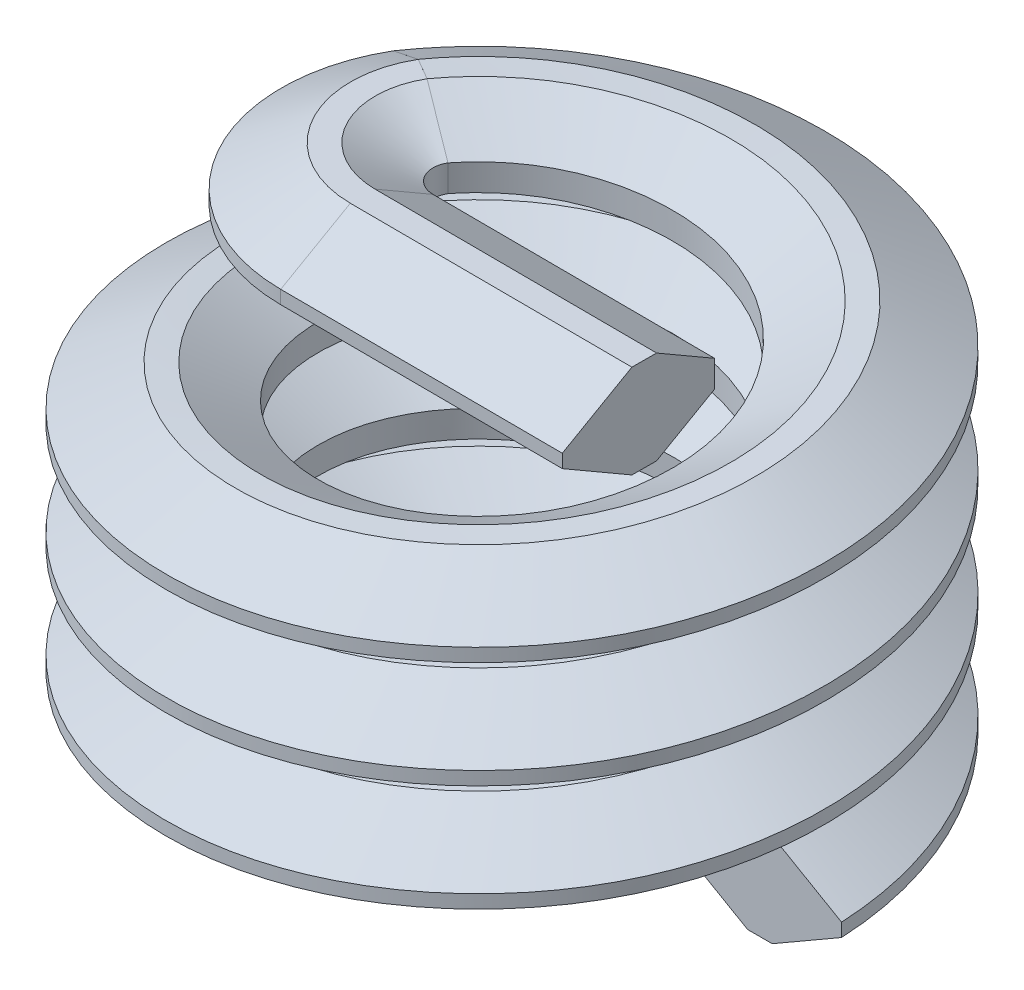
from build123d import *

# Parameters (mm, degrees)
SWEEP1_PITCH       = 0.79375
SWEEP1_HEIGHT      = 2.71145
SWEEP1_RADIUS      = 1.7526
SWEEP1_START_ANGLE = 90
REVOLVE1_ANGLE     = 120
EXTRUDE1_DEPTH     = 2.10312


with BuildPart() as part:
    # Sweep1: sweep along a helix
    with BuildLine() as sweep1_path:
        add(Helix(SWEEP1_PITCH, SWEEP1_HEIGHT, SWEEP1_RADIUS, center=(0, 0, 0), direction=(0, 1, 0), mode=Mode.PRIVATE).rotate(Axis((0, 0, 0), (0, 1, 0)), SWEEP1_START_ANGLE))
    # Sketch1 → Sweep1 (sweep)
    with BuildSketch(Plane(origin=(0, 0, 0), x_dir=(-1, 0, 0), z_dir=(0, 0, 1))):
        Polygon((-2.4511, -0.049609375), (-1.935544252, -0.347265625), (-1.7526, -0.347265625), (-1.32297021, -0.09921875), (-1.32297021, 0.09921875), (-1.7526, 0.347265625), (-1.935544252, 0.347265625), (-2.4511, 0.049609375), align=None)
    sweep(path=sweep1_path.line, is_frenet=True)


with BuildPart() as body_2:
    # Sketch3 → Revolve1 (revolve)
    with BuildSketch(Plane(origin=(0, 0, 0), x_dir=(0.863937822, 0, 0.503598491), z_dir=(-0.503598491, 0, 0.863937822))):
        Polygon((-1.7526, 2.363793834), (-1.32297021, 2.611841495), (-1.32297021, 2.810278209), (-1.7526, 3.058323921), (-1.935544251, 3.058323273), (-2.451099999, 2.760667023), (-2.4511, 2.661448597), (-1.935544252, 2.363793048), align=None)
    revolve(axis=Axis((-0.994495107, 2.711060242, -0.579701713), (0, 1, 0)), revolution_arc=REVOLVE1_ANGLE)

    # Sketch4 → Extrude1 (add)
    with BuildSketch(Plane(origin=(-0.996889536, 0, -0.004147271), x_dir=(0.004160175, 0, -0.999991346), z_dir=(0.999991346, 0, 0.004160175))):
        with BuildLine():
            Line((-0.208865986, 2.363793047), (-0.025921734, 2.363793833))
            Line((-0.025921734, 2.363793833), (0.403708056, 2.611841495))
            Line((0.403708056, 2.611841495), (0.403708056, 2.810278209))
            Line((0.403708056, 2.810278209), (-0.025921734, 3.05832392))
            add(Edge.make_bspline(
                [(-0.025921734, 3.05832392), (-0.208865986, 3.058323273)],
                knots=[0, 0, 1, 1], degree=1))
            Line((-0.208865986, 3.058323273), (-0.724421734, 2.760667022))
            Line((-0.724421734, 2.760667022), (-0.724421734, 2.661448596))
            Line((-0.724421734, 2.661448596), (-0.208865986, 2.363793047))
        make_face()
    extrude(amount=EXTRUDE1_DEPTH)


solid = Compound([part.part, body_2.part])
